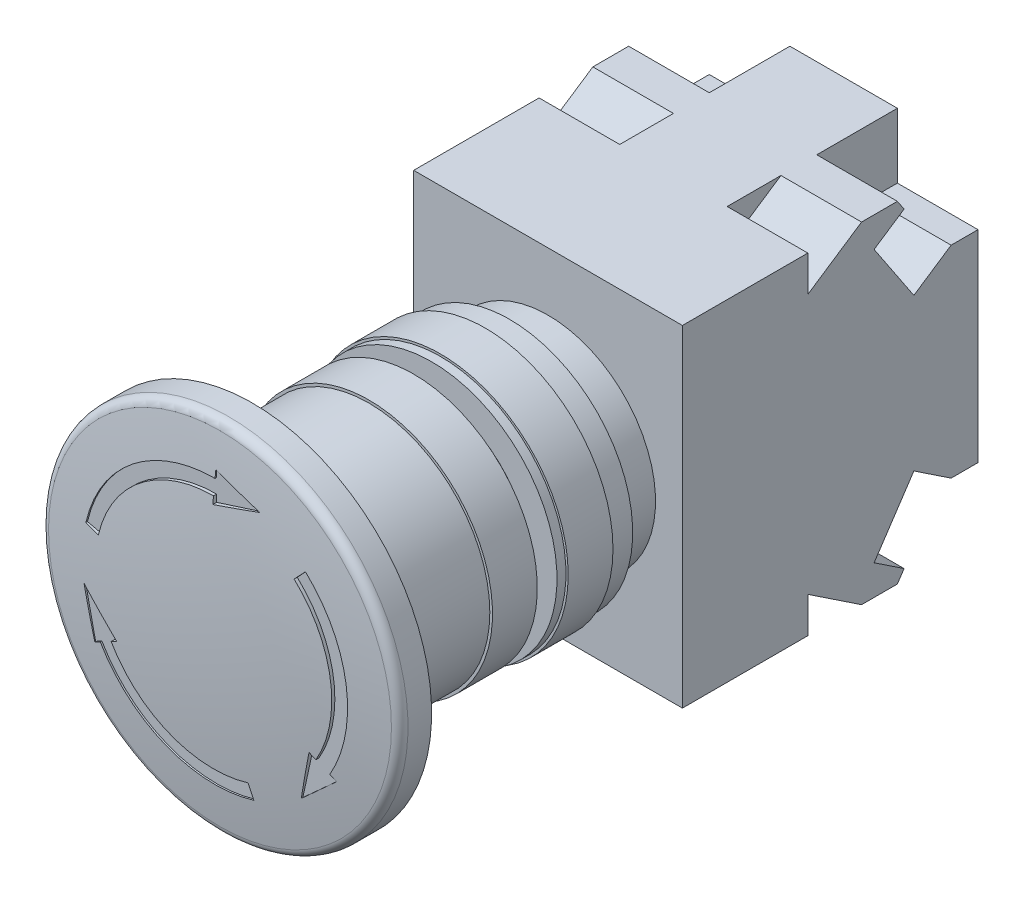
from build123d import *

# Parameters (mm, degrees)
ESQUISSE1_W             = 33
ESQUISSE1_H             = 37
BOSS_EXTRU_1_DEPTH      = 15
ENL_V_MAT_EXTRU_1_DEPTH = 9
ENL_V_MAT_EXTRU_2_DEPTH = 9
ESQUISSE4_R             = 12
BOSS_EXTRU_2_DEPTH      = 8
ESQUISSE5_R             = 11
BOSS_EXTRU_3_DEPTH      = 8.5
ESQUISSE6_R             = 7.775
BOSS_EXTRU_4_DEPTH      = 5.8
ESQUISSE7_R             = 10
BOSS_EXTRU_5_DEPTH      = 4
ESQUISSE8_R             = 8.5
BOSS_EXTRU_6_DEPTH      = 5
ESQUISSE10_W            = 1
ESQUISSE10_H            = 3
CONG_1_R                = 1
ENL_V_MAT_EXTRU_3_DEPTH = 1


with BuildPart() as part:
    # Esquisse1 → Boss.-Extru.1 (new body, symmetric)
    with BuildSketch(Plane(origin=(0, 0, 0), x_dir=(0, 0, -1), z_dir=(1, 0, 0))):
        with Locations((-16.5, 0)):
            Rectangle(ESQUISSE1_W, ESQUISSE1_H)
    extrude(amount=BOSS_EXTRU_1_DEPTH, both=True)

    # Esquisse2 → Enlèv. mat.-Extru.1 (cut)
    with BuildSketch(Plane(origin=(15, 0, 0), x_dir=(0, 0, -1), z_dir=(1, 0, 0))):
        Polygon((-9, -18.5), (-8.251601476, -17.377402213), (-11.597853041, -15.146567836), (-7.160251472, -8.490165481), (-3, -11.263666462), (0, -11.263666462), (0, -20.603237272), (-19, -20.603237272), (-19, -18.5), (-19, -14.5), (-13, -18.5), align=None)
        Polygon((-19, 20.603237272), (0, 20.603237272), (0, 11.263666462), (-3, 11.263666462), (-7.160251472, 8.490165481), (-11.597853041, 15.146567836), (-8.251601476, 17.377402213), (-9, 18.5), (-13, 18.5), (-19, 14.5), (-19, 18.5), align=None)
    extrude(amount=-ENL_V_MAT_EXTRU_1_DEPTH, mode=Mode.SUBTRACT)

    # Esquisse3 → Enlèv. mat.-Extru.2 (cut)
    with BuildSketch(Plane.ZY.offset(15)):
        Polygon((-2.98504772, 11.263666462), (3, 11.263666462), (7.160251472, 8.490165481), (11.597853041, 15.146567836), (8.251601476, 17.377402213), (9, 18.5), (13, 18.5), (19, 14.5), (19, 18.5), (21.50409999, 22.256149985), (-2.98504772, 22.256149985), align=None)
        Polygon((-2.98504772, -22.256149985), (-2.98504772, -11.263666462), (3, -11.263666462), (7.160251472, -8.490165481), (11.597853041, -15.146567836), (8.251601476, -17.377402213), (9, -18.5), (13, -18.5), (19, -14.5), (19, -18.5), (21.50409999, -22.256149985), align=None)
    extrude(amount=-ENL_V_MAT_EXTRU_2_DEPTH, mode=Mode.SUBTRACT)

    # Esquisse4 → Boss.-Extru.2 (add)
    with BuildSketch(Plane.XY.offset(33)):
        Circle(ESQUISSE4_R)
    extrude(amount=BOSS_EXTRU_2_DEPTH)

    # Esquisse5 → Boss.-Extru.3 (add)
    with BuildSketch(Plane.XY.offset(41)):
        Circle(ESQUISSE5_R)
    extrude(amount=BOSS_EXTRU_3_DEPTH)

    # Esquisse6 → Boss.-Extru.4 (add)
    with BuildSketch(Plane.XY.offset(49.5)):
        Circle(ESQUISSE6_R)
    extrude(amount=BOSS_EXTRU_4_DEPTH)

    # Esquisse7 → Boss.-Extru.5 (add)
    with BuildSketch(Plane.XY.offset(55.3)):
        Circle(ESQUISSE7_R)
    extrude(amount=BOSS_EXTRU_5_DEPTH)

    # Esquisse8 → Boss.-Extru.6 (add)
    with BuildSketch(Plane.XY.offset(59.3)):
        Circle(ESQUISSE8_R)
    extrude(amount=BOSS_EXTRU_6_DEPTH)


with BuildPart() as body_2:
    # Esquisse9 → Révolution1 (revolve)
    with BuildSketch(Plane(origin=(0, 0, 0), x_dir=(0, 0, -1), z_dir=(1, 0, 0))):
        Polygon((-45, 12), (-37.3, 12), (-37.3, 13.75), (-40, 13.75), (-40, 14.25), (-45, 14.25), align=None)
    revolve(axis=Axis((0, 0, -56.84), (0, 0, 1)))


with BuildPart() as body_3:
    # Esquisse10 → Révolution2 (revolve)
    with BuildSketch(Plane(origin=(0, 0, 0), x_dir=(0, 0, -1), z_dir=(1, 0, 0))):
        with Locations((-45.5, 12.5)):
            Rectangle(ESQUISSE10_W, ESQUISSE10_H)
    revolve(axis=Axis((0, 0, -56.84), (0, 0, 1)))


with BuildPart() as body_4:
    # Esquisse11 → Révolution3 (revolve)
    with BuildSketch(Plane(origin=(0, 0, 0), x_dir=(0, 0, -1), z_dir=(1, 0, 0))):
        Polygon((-48, 11), (-48, 13.8), (-53, 13.8), (-53, 13.5), (-62, 13.5), (-62, 11), align=None)
    revolve(axis=Axis((0, 0, -56.84), (0, 0, 1)))


with BuildPart() as body_5:
    # Esquisse12 → Révolution4 (revolve)
    with BuildSketch(Plane(origin=(0, 0, 0), x_dir=(0, 0, -1), z_dir=(1, 0, 0))):
        with BuildLine():
            Line((-69.5, 11.25), (-60.5, 11.25))
            Line((-60.5, 11.25), (-60.5, 8.5))
            Line((-60.5, 8.5), (-69.5, 8.5))
            Line((-69.5, 8.5), (-69.5, 0))
            Line((-69.5, 0), (-71, 0))
            ThreePointArc((-71, 0), (-70.624474134, 10.02808556), (-69.5, 20))
            Line((-69.5, 20), (-66, 20))
            Line((-66, 20), (-66, 18.5))
            Line((-66, 18.5), (-68.5, 18.5))
            ThreePointArc((-68.5, 18.5), (-69.248822118, 14.909320292), (-69.5, 11.25))
        make_face()
    revolve(axis=Axis((0, 0, -56.84), (0, 0, 1)))

    # Congé1
    cong_1_edges = [body_5.edges().sort_by_distance(p)[0] for p in [
        (0, -18.5, 68.5),
        (0, -20, 69.5),
    ]]
    fillet(cong_1_edges, radius=CONG_1_R)

    # Esquisse13 → Enlèv. mat.-Extru.3 (cut)
    with BuildSketch(Plane.XY.offset(71)):
        with BuildLine():
            Line((0, 15.6), (0, 14.8))
            ThreePointArc((0, 14.8), (-9.214255263, 11.581774473), (-14.421273837, 3.326689182))
            Line((-14.421273837, 3.326689182), (-12.862217206, 2.967047108))
            ThreePointArc((-12.862217206, 2.967047108), (-8.218119559, 10.329690746), (0, 13.2))
            Line((0, 13.2), (0, 12.4))
            Line((0, 12.4), (5, 14))
            Line((5, 14), (0, 15.6))
        make_face()
        with BuildLine():
            Line((9.000646773, 9.655483295), (10.091634261, 10.825844907))
            ThreePointArc((10.091634261, 10.825844907), (14.637238546, 2.188891898), (12.817175976, -7.4))
            Line((12.817175976, -7.4), (13.509996299, -7.8))
            Line((13.509996299, -7.8), (9.624355653, -11.330127019))
            Line((9.624355653, -11.330127019), (10.738715007, -6.2))
            Line((10.738715007, -6.2), (11.43153533, -6.6))
            ThreePointArc((11.43153533, -6.6), (13.054834379, 1.952254936), (9.000646773, 9.655483295))
        make_face()
        with BuildLine():
            Line((3.861570433, -12.622530404), (4.329639576, -14.152534089))
            ThreePointArc((4.329639576, -14.152534089), (-5.422983283, -13.770666371), (-12.817175976, -7.4))
            Line((-12.817175976, -7.4), (-13.509996299, -7.8))
            Line((-13.509996299, -7.8), (-14.624355653, -2.669872981))
            Line((-14.624355653, -2.669872981), (-10.738715007, -6.2))
            Line((-10.738715007, -6.2), (-11.43153533, -6.6))
            ThreePointArc((-11.43153533, -6.6), (-4.83671482, -12.281945683), (3.861570433, -12.622530404))
        make_face()
    extrude(amount=-ENL_V_MAT_EXTRU_3_DEPTH, mode=Mode.SUBTRACT)


solid = Compound([part.part, body_2.part, body_3.part, body_4.part, body_5.part])
